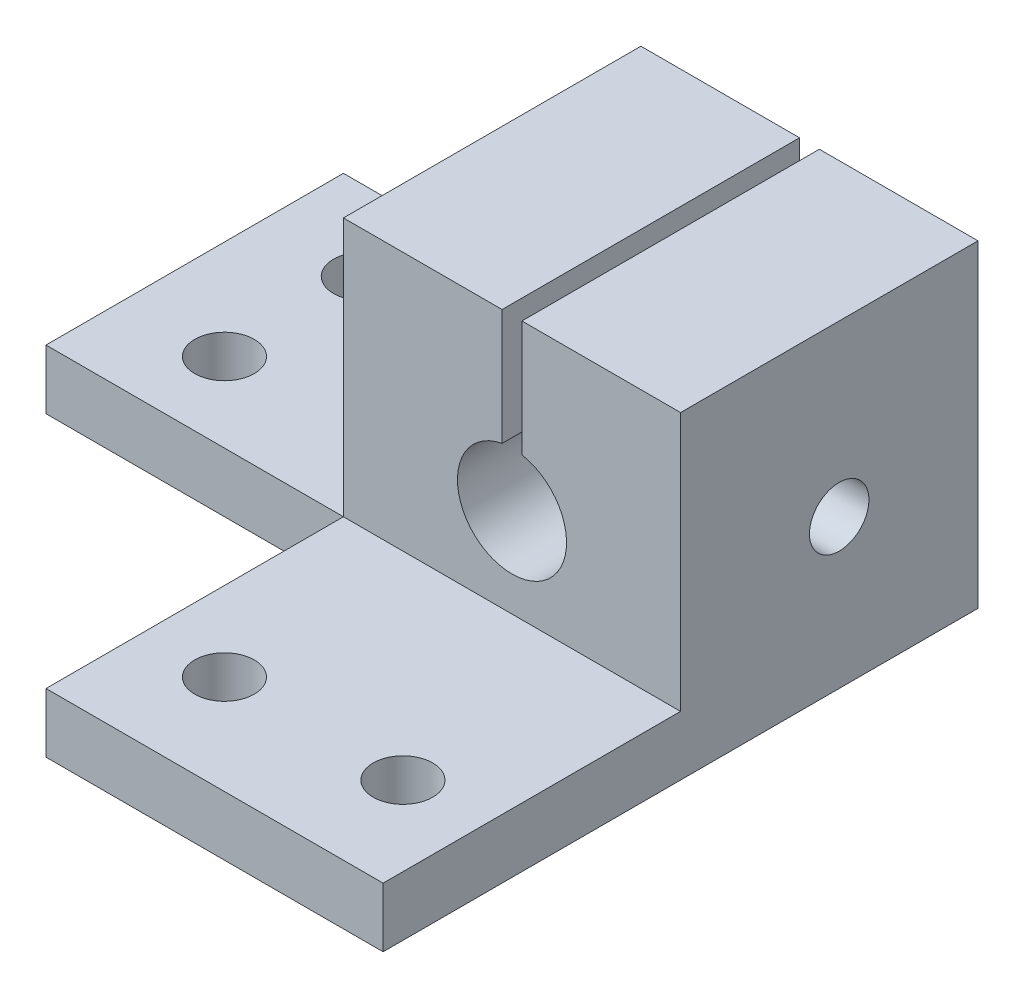
from build123d import *

# Parameters (mm, degrees)
CROQUIS1_W              = 17
CROQUIS1_H              = 15
SALIENTE_EXTRUIR1_DEPTH = 20
CROQUIS2_R              = 2.75
CORTAR_EXTRUIR1_DEPTH   = 20
CROQUIS4_R              = 1.5
CORTAR_EXTRUIR3_DEPTH   = 20
CROQUIS7_W              = 8
CROQUIS7_H              = 3.948353597
CORTAR_EXTRUIR5_DEPTH   = 35
CROQUIS8_W              = 17
CROQUIS8_H              = 3
SALIENTE_EXTRUIR2_DEPTH = 15
CROQUIS9_W              = 15
CROQUIS9_H              = 3
SALIENTE_EXTRUIR3_DEPTH = 15
CROQUIS10_R             = 1.5
CORTAR_EXTRUIR6_DEPTH   = 10


with BuildPart() as part:
    # Croquis1 → Saliente-Extruir1 (new body)
    with BuildSketch(Plane(origin=(0, 0, 0), x_dir=(1, 0, 0), z_dir=(0, 1, 0))):
        Rectangle(CROQUIS1_W, CROQUIS1_H)
    extrude(amount=SALIENTE_EXTRUIR1_DEPTH)

    # Croquis2 → Cortar-Extruir1 (cut)
    with BuildSketch(Plane(origin=(0, 0, -7.5), x_dir=(-1, 0, 0), z_dir=(0, 0, -1))):
        with Locations((0, 7.5)):
            Circle(CROQUIS2_R)
        with BuildLine():
            Line((0.5, 20), (-0.5, 20))
            Line((-0.5, 20), (-0.5, 10.204163457))
            ThreePointArc((-0.5, 10.204163457), (0, 10.25), (0.5, 10.204163457))
            Line((0.5, 10.204163457), (0.5, 20))
        make_face()
    extrude(amount=-CORTAR_EXTRUIR1_DEPTH, mode=Mode.SUBTRACT)

    # Croquis4 → Cortar-Extruir3 (cut)
    with BuildSketch(Plane.ZY.offset(8.5)):
        with Locations((-0.5, 7.5)):
            Circle(CROQUIS4_R)
    extrude(amount=-CORTAR_EXTRUIR3_DEPTH, mode=Mode.SUBTRACT)

    # Croquis7 → Cortar-Extruir5 (cut)
    with BuildSketch(Plane.XY.offset(7.5)):
        with Locations((4.5, 18.025823201)):
            Rectangle(CROQUIS7_W, CROQUIS7_H)
        with Locations((-4.5, 18.025823201)):
            Rectangle(CROQUIS7_W, CROQUIS7_H)
    extrude(amount=-CORTAR_EXTRUIR5_DEPTH, mode=Mode.SUBTRACT)

    # Croquis8 → Saliente-Extruir2 (add)
    with BuildSketch(Plane.XY.offset(7.5)):
        with Locations((0, 1.5)):
            Rectangle(CROQUIS8_W, CROQUIS8_H)
    extrude(amount=SALIENTE_EXTRUIR2_DEPTH)

    # Croquis9 → Saliente-Extruir3 (add)
    with BuildSketch(Plane.ZY.offset(8.5)):
        with Locations((0, 1.5)):
            Rectangle(CROQUIS9_W, CROQUIS9_H)
    extrude(amount=SALIENTE_EXTRUIR3_DEPTH)

    # Croquis10 → Cortar-Extruir6 (cut)
    with BuildSketch(Plane.XZ):
        with Locations((-18.5, -3.5)):
            Circle(CROQUIS10_R)
        with Locations((-4.5, 17.5)):
            Circle(CROQUIS10_R)
        with Locations((4.5, 17.5)):
            Circle(CROQUIS10_R)
        with Locations((-18.5, 3.5)):
            Circle(CROQUIS10_R)
    extrude(amount=-CORTAR_EXTRUIR6_DEPTH, mode=Mode.SUBTRACT)


solid = part.part
